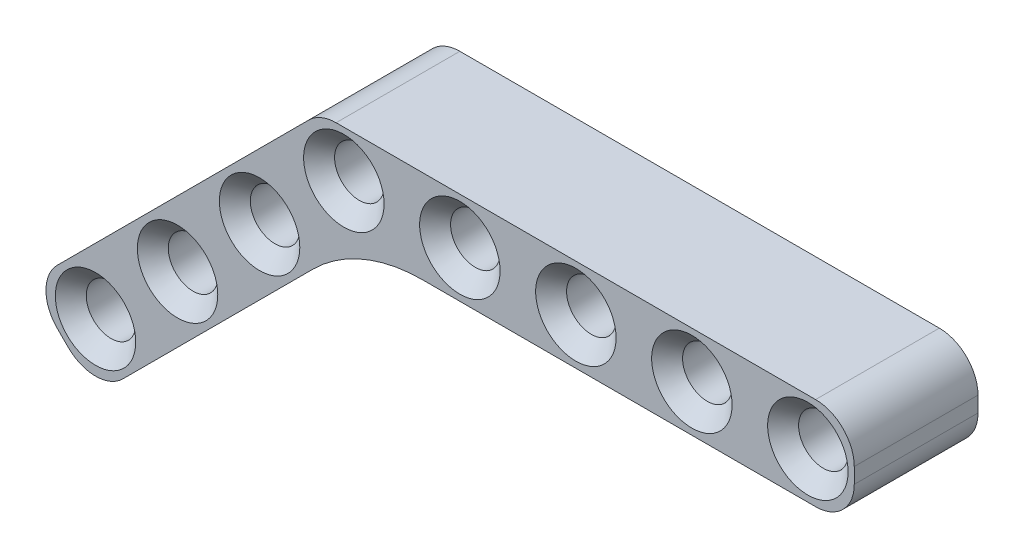
from build123d import *

# Parameters (mm, degrees)
SKETCH1_R           = 1.6
BOSS_EXTRUDE1_DEPTH = 8
CHAMFER1_SIZE       = 1
SKETCH2_R           = 1.6
BOSS_EXTRUDE3_DEPTH = 8
FILLET1_R           = 10
CHAMFER2_SIZE       = 1


with BuildPart() as part:
    # Sketch1 → Boss-Extrude1 (new body)
    with BuildSketch(Plane.XY):
        with BuildLine():
            Line((-0.5, 3), (30.5, 3))
            ThreePointArc((30.5, 3), (32.267766953, 2.267766953), (33, 0.5))
            Line((33, 0.5), (33, -0.5))
            ThreePointArc((33, -0.5), (32.267766953, -2.267766953), (30.5, -3))
            Line((30.5, -3), (-0.5, -3))
            ThreePointArc((-0.5, -3), (-2.267766953, -2.267766953), (-3, -0.5))
            Line((-3, -0.5), (-3, 0.5))
            ThreePointArc((-3, 0.5), (-2.267766953, 2.267766953), (-0.5, 3))
        make_face()
        Circle(SKETCH1_R, mode=Mode.SUBTRACT)
        with Locations((7.5, 0)):
            Circle(SKETCH1_R, mode=Mode.SUBTRACT)
        with Locations((15, 0)):
            Circle(SKETCH1_R, mode=Mode.SUBTRACT)
        with Locations((22.5, 0)):
            Circle(SKETCH1_R, mode=Mode.SUBTRACT)
        with Locations((30, 0)):
            Circle(SKETCH1_R, mode=Mode.SUBTRACT)
    extrude(amount=BOSS_EXTRUDE1_DEPTH)

    # Chamfer1
    chamfer1_edges = [part.edges().sort_by_distance(p)[0] for p in [
        (-1.6, 0, 0),
        (-1.6, 0, 8),
        (5.9, 0, 0),
        (5.9, 0, 8),
        (13.4, 0, 0),
        (13.4, 0, 8),
        (20.9, 0, 0),
        (20.9, 0, 8),
        (28.4, 0, 0),
        (28.4, 0, 8),
    ]]
    chamfer(chamfer1_edges, length=CHAMFER1_SIZE)

    # Sketch2 → Boss-Extrude3 (add)
    with BuildSketch(Plane.XY.offset(8)):
        with BuildLine():
            ThreePointArc((-3, 0.5), (-2.809698831, 1.456708581), (-2.267766953, 2.267766953))
            Line((-2.267766953, 2.267766953), (-18.529200529, -13.993666623))
            ThreePointArc((-18.529200529, -13.993666623), (-19.261433576, -15.761433576), (-18.529200529, -17.529200529))
            Line((-18.529200529, -17.529200529), (-17.822093748, -18.23630731))
            ThreePointArc((-17.822093748, -18.23630731), (-16.054326795, -18.968540357), (-14.286559842, -18.23630731))
            Line((-14.286559842, -18.23630731), (0.949747468, -3))
            Line((0.949747468, -3), (-0.5, -3))
            ThreePointArc((-0.5, -3), (-2.267766953, -2.267766953), (-3, -0.5))
            Line((-3, -0.5), (-3, 0.5))
        make_face()
        with Locations((-16.054326795, -15.761433576)):
            Circle(SKETCH2_R, mode=Mode.SUBTRACT)
        with Locations((-10.751025936, -10.458132717)):
            Circle(SKETCH2_R, mode=Mode.SUBTRACT)
        with Locations((-5.447725077, -5.154831858)):
            Circle(SKETCH2_R, mode=Mode.SUBTRACT)
    extrude(amount=-BOSS_EXTRUDE3_DEPTH)

    # Fillet1
    fillet1_edges = [part.edges().sort_by_distance(p)[0] for p in [
        (0.949747468, -3, 4),
    ]]
    fillet(fillet1_edges, radius=FILLET1_R)

    # Chamfer2
    chamfer2_edges = [part.edges().sort_by_distance(p)[0] for p in [
        (-17.654326795, -15.761433576, 8),
        (-12.351025936, -10.458132717, 8),
        (-7.047725077, -5.154831858, 8),
        (-7.047725077, -5.154831858, 0),
        (-12.351025936, -10.458132717, 0),
        (-17.654326795, -15.761433576, 0),
    ]]
    chamfer(chamfer2_edges, length=CHAMFER2_SIZE)


solid = part.part
